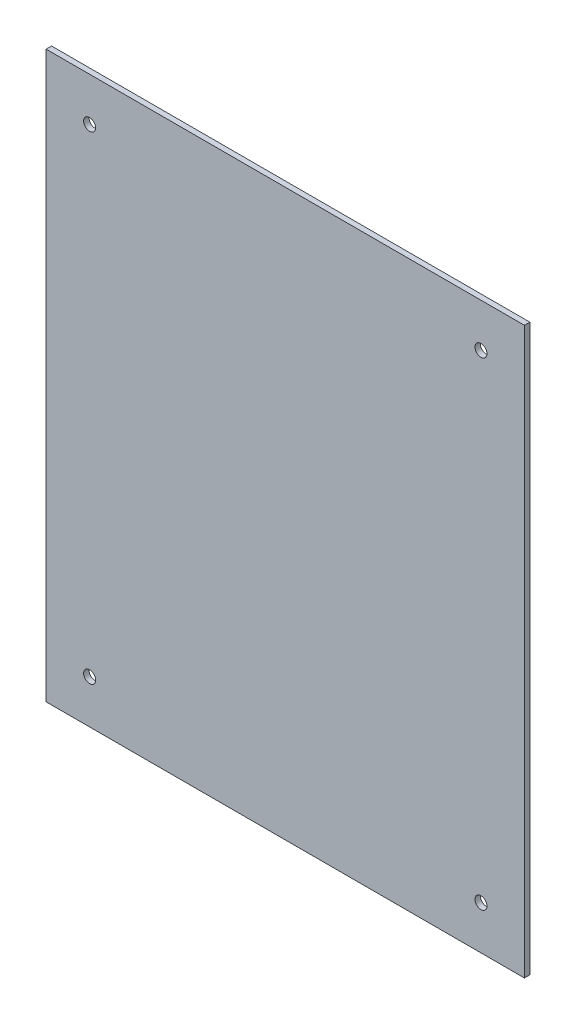
from build123d import *

# Parameters (mm, degrees)
SKETCH1_W           = 279.4
SKETCH1_H           = 330.2
SKETCH1_R           = 3.5
BOSS_EXTRUDE1_DEPTH = 3.175


with BuildPart() as part:
    # Sketch1 → Boss-Extrude1 (new body)
    with BuildSketch(Plane.XY):
        Rectangle(SKETCH1_W, SKETCH1_H)
        with Locations((-114.3, 139.7)):
            Circle(SKETCH1_R, mode=Mode.SUBTRACT)
        with Locations((114.3, 139.7)):
            Circle(SKETCH1_R, mode=Mode.SUBTRACT)
        with Locations((-114.3, -139.7)):
            Circle(SKETCH1_R, mode=Mode.SUBTRACT)
        with Locations((114.3, -139.7)):
            Circle(SKETCH1_R, mode=Mode.SUBTRACT)
    extrude(amount=BOSS_EXTRUDE1_DEPTH)


solid = part.part
